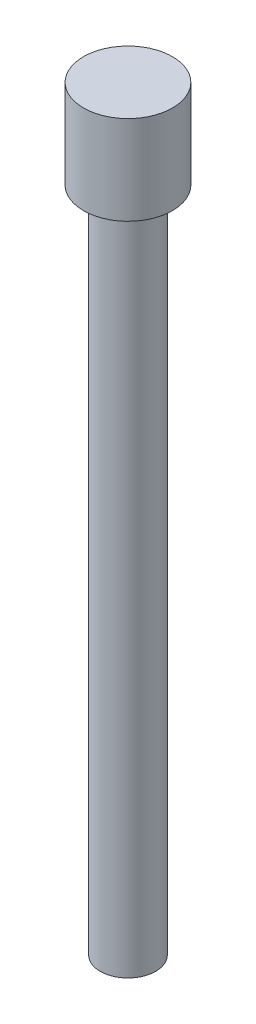
from build123d import *

# Parameters (mm, degrees)
SKETCH1_R           = 1.25
BOSS_EXTRUDE1_DEPTH = 30
SKETCH2_R           = 2
BOSS_EXTRUDE2_DEPTH = 4


with BuildPart() as part:
    # Sketch1 → Boss-Extrude1 (new body)
    with BuildSketch(Plane(origin=(0, 0, 0), x_dir=(1, 0, 0), z_dir=(0, 1, 0))):
        Circle(SKETCH1_R)
    extrude(amount=BOSS_EXTRUDE1_DEPTH)

    # Sketch2 → Boss-Extrude2 (add)
    with BuildSketch(Plane(origin=(0, 30, 0), x_dir=(1, 0, 0), z_dir=(0, 1, 0))):
        Circle(SKETCH2_R)
    extrude(amount=BOSS_EXTRUDE2_DEPTH)


solid = part.part
